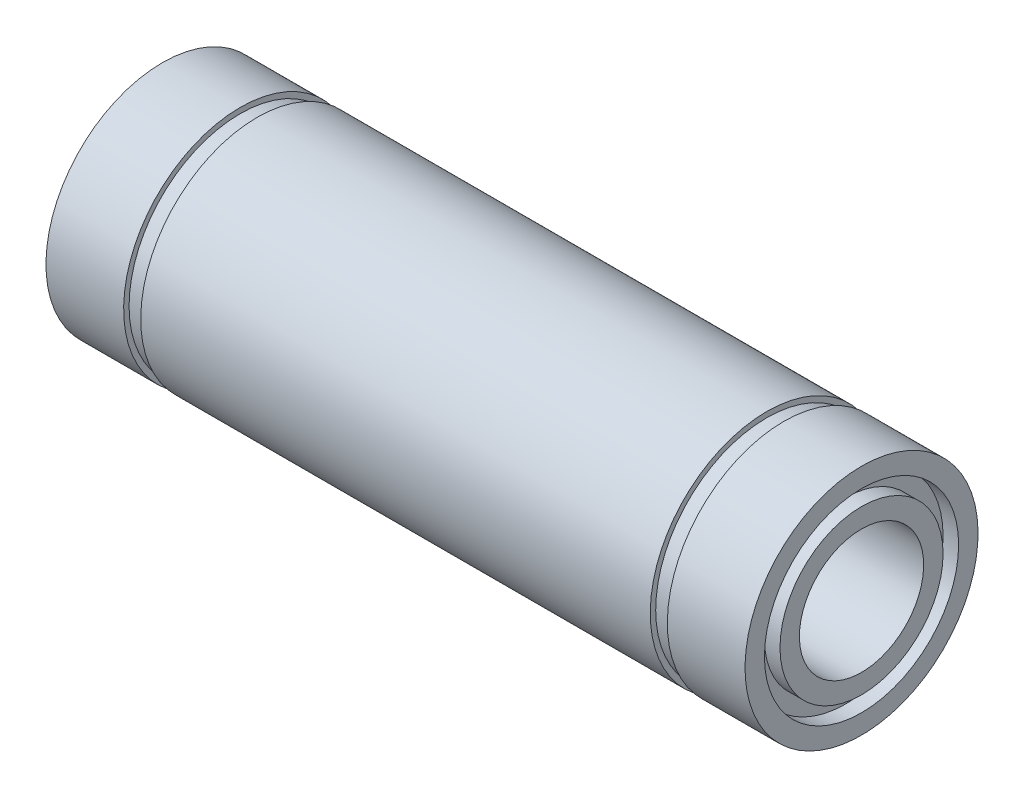
from build123d import *


with BuildPart() as part:
    # Esboço1 → Revolução1 (revolve)
    with BuildSketch(Plane.XY):
        Polygon((-22.5, 7.5), (-17.5, 7.5), (-17.5, 7.15), (-16.4, 7.15), (-16.4, 7.5), (16.4, 7.5), (16.4, 7.15), (17.5, 7.15), (17.5, 7.5), (22.5, 7.5), (22.5, 6.25), (21.5, 6.25), (21.5, 5.25), (22.5, 5.25), (22.5, 4), (-22.5, 4), (-22.5, 5.25), (-21.5, 5.25), (-21.5, 6.25), (-22.5, 6.25), align=None)
    revolve(axis=Axis((0, 0, 0), (-1, 0, 0)))


solid = part.part
